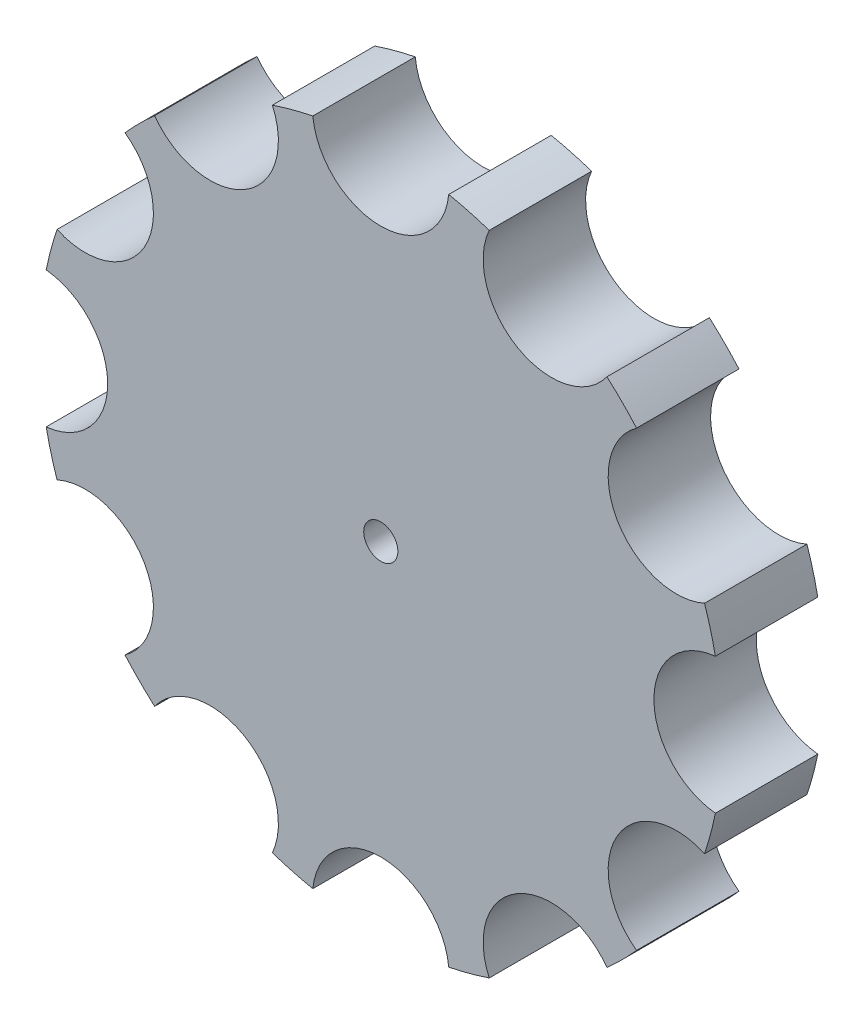
from build123d import *

# Parameters (mm, degrees)
BOSS_EXTRUDE3_DEPTH = 15
SKETCH3_R           = 2.5
CUT_EXTRUDE2_DEPTH  = 15


with BuildPart() as part:
    # Sketch1 → Boss-Extrude3 (new body)
    with BuildSketch(Plane.XY):
        with BuildLine():
            ThreePointArc((48.999319531, 9.953224878), (48.296291314, 12.940952255), (47.411267921, 15.879914172))
            ThreePointArc((47.411267921, 15.879914172), (34.638070137, 19.998299118), (37.458043043, 33.119405359))
            ThreePointArc((37.458043043, 33.119405359), (35.355339059, 35.355339059), (33.119405359, 37.458043043))
            ThreePointArc((33.119405359, 37.458043043), (19.998299118, 34.638070137), (15.879914172, 47.411267921))
            ThreePointArc((15.879914172, 47.411267921), (12.940952255, 48.296291314), (9.953224878, 48.999319531))
            ThreePointArc((9.953224878, 48.999319531), (0, 39.996598235), (-9.953224878, 48.999319531))
            ThreePointArc((-9.953224878, 48.999319531), (-12.940952255, 48.296291314), (-15.879914172, 47.411267921))
            ThreePointArc((-15.879914172, 47.411267921), (-19.998299118, 34.638070137), (-33.119405359, 37.458043043))
            ThreePointArc((-33.119405359, 37.458043043), (-35.355339059, 35.355339059), (-37.458043043, 33.119405359))
            ThreePointArc((-37.458043043, 33.119405359), (-34.638070137, 19.998299118), (-47.411267921, 15.879914172))
            ThreePointArc((-47.411267921, 15.879914172), (-48.296291314, 12.940952255), (-48.999319531, 9.953224878))
            ThreePointArc((-48.999319531, 9.953224878), (-39.996598235, 0), (-48.999319531, -9.953224878))
            ThreePointArc((-48.999319531, -9.953224878), (-48.296291314, -12.940952255), (-47.411267921, -15.879914172))
            ThreePointArc((-47.411267921, -15.879914172), (-34.638070137, -19.998299118), (-37.458043043, -33.119405359))
            ThreePointArc((-37.458043043, -33.119405359), (-35.355339059, -35.355339059), (-33.119405359, -37.458043043))
            ThreePointArc((-33.119405359, -37.458043043), (-19.998299118, -34.638070137), (-15.879914172, -47.411267921))
            ThreePointArc((-15.879914172, -47.411267921), (-12.940952255, -48.296291314), (-9.953224878, -48.999319531))
            ThreePointArc((-9.953224878, -48.999319531), (0, -39.996598235), (9.953224878, -48.999319531))
            ThreePointArc((9.953224878, -48.999319531), (12.940952255, -48.296291314), (15.879914172, -47.411267921))
            ThreePointArc((15.879914172, -47.411267921), (19.998299118, -34.638070137), (33.119405359, -37.458043043))
            ThreePointArc((33.119405359, -37.458043043), (35.355339059, -35.355339059), (37.458043043, -33.119405359))
            ThreePointArc((37.458043043, -33.119405359), (34.638070137, -19.998299118), (47.411267921, -15.879914172))
            ThreePointArc((47.411267921, -15.879914172), (48.296291314, -12.940952255), (48.999319531, -9.953224878))
            ThreePointArc((48.999319531, -9.953224878), (39.996598235, 0), (48.999319531, 9.953224878))
        make_face()
    extrude(amount=BOSS_EXTRUDE3_DEPTH)

    # Sketch3 → Cut-Extrude2 (cut)
    with BuildSketch(Plane(origin=(0, 0, 0), x_dir=(-1, 0, 0), z_dir=(0, 0, -1))):
        Circle(SKETCH3_R)
    extrude(amount=-CUT_EXTRUDE2_DEPTH, mode=Mode.SUBTRACT)


solid = part.part
